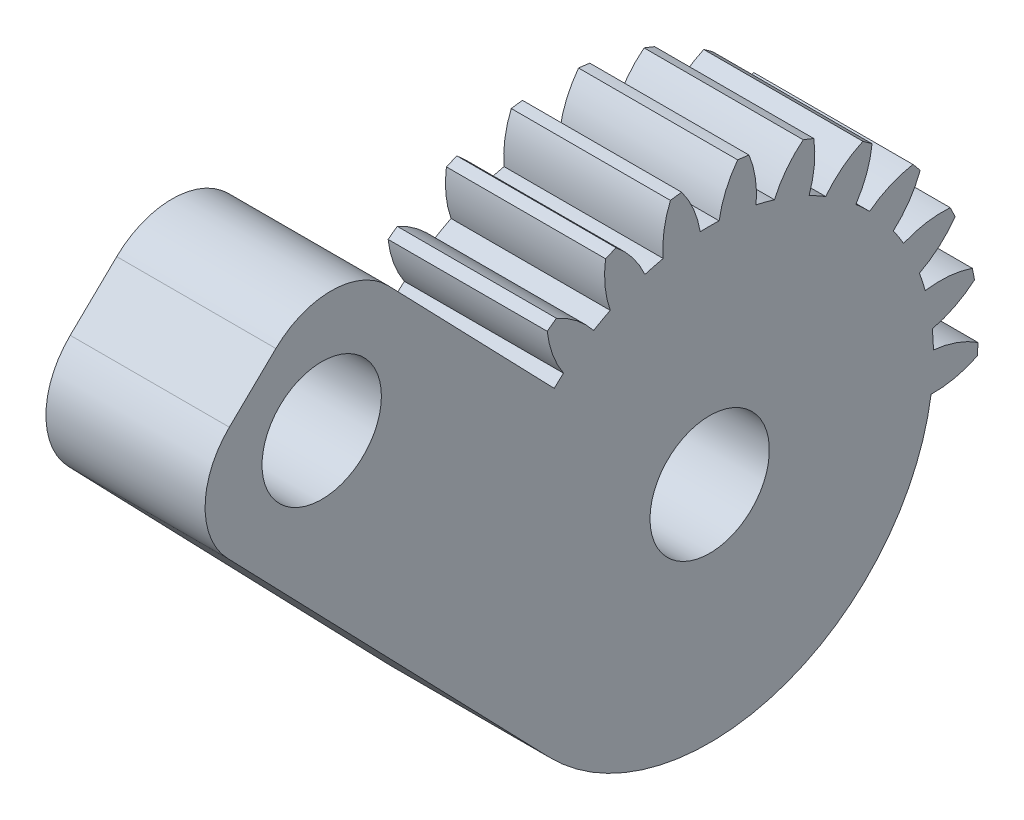
from build123d import *

# Parameters (mm, degrees)
BASPROSKE_W                  = 20
BASPROSKE_H                  = 33.75
BASE_REVOLVE_ANGLE           = 134
BASE_REVOLVE_OTHER_WAY_ANGLE = 11
TOOTHCUT_DEPTH               = 52.750603861
TEETHCUTS_COUNT              = 25
TEETHCUTS_ANGLE              = 345.6
BORSKE_R                     = 7.5
BORE_DEPTH                   = 50.000508
BOSS_EXTRUDE1_DEPTH          = 20
SKETCH5_R                    = 7.5
CUT_EXTRUDE1_DEPTH           = 20
FILLET1_R                    = 10
FILLET2_R                    = 10
SCALE1_SCALE                 = 0.8


with BuildPart() as part:
    # BasProSke → Base-Revolve (revolve)
    with BuildSketch(Plane(origin=(0, 0, 0), x_dir=(1, 0, 0), z_dir=(0, 1, 0))):
        with Locations((10, 16.875)):
            Rectangle(BASPROSKE_W, BASPROSKE_H)
    revolve(axis=Axis((-10, 0, 0), (1, 0, 0)), revolution_arc=BASE_REVOLVE_ANGLE)

    # BasProSke → Base-Revolve other way (revolve)
    with BuildSketch(Plane(origin=(0, 0, 0), x_dir=(1, 0, 0), z_dir=(0, 1, 0))):
        with Locations((10, 16.875)):
            Rectangle(BASPROSKE_W, BASPROSKE_H)
    revolve(axis=Axis((-10, 0, 0), (-1, 0, 0)), revolution_arc=BASE_REVOLVE_OTHER_WAY_ANGLE)

    # TooCutSke → ToothCut (cut, through all)
    with BuildSketch(Plane(origin=(0, 0, 0), x_dir=(0, 0, -1), z_dir=(1, 0, 0))):
        with BuildLine():
            ThreePointArc((1.187856988, 28.098903391), (0, 28.124), (-1.187856988, 28.098903391))
            ThreePointArc((-1.187856988, 28.098903391), (-2.083835169, 31.109603364), (-3.702102288, 33.801870579))
            ThreePointArc((-3.702102288, 33.801870579), (0, 34.004), (3.702102288, 33.801870579))
            ThreePointArc((3.702102288, 33.801870579), (2.083835169, 31.109603364), (1.187856988, 28.098903391))
        make_face()
    toothcut = extrude(amount=TOOTHCUT_DEPTH, mode=Mode.SUBTRACT)

    # TeethCuts: ToothCut ×25 about axis
    teethcuts_axis = Axis((-10, 0, 0), (1, 0, 0))
    for i in range(1, TEETHCUTS_COUNT):
        add(toothcut.rotate(teethcuts_axis, i * TEETHCUTS_ANGLE / (TEETHCUTS_COUNT - 1)), mode=Mode.SUBTRACT)

    # BorSke → Bore (cut, symmetric)
    with BuildSketch(Plane(origin=(0, 0, 0), x_dir=(0, 0, -1), z_dir=(1, 0, 0))):
        Circle(BORSKE_R)
    extrude(amount=BORE_DEPTH, both=True, mode=Mode.SUBTRACT)

    # Sketch4 → Boss-Extrude1 (add)
    with BuildSketch(Plane(origin=(20, 0, 0), x_dir=(0, 0, -1), z_dir=(1, 0, 0))):
        with BuildLine():
            Line((-67.553619374, 29.467732547), (-20.230712545, -19.536572011))
            ThreePointArc((-20.230712545, -19.536572011), (7.987647554, -26.965846223), (27.607282907, -5.366312186))
            Line((27.607282907, -5.366312186), (7.362203876, -1.431067465))
            ThreePointArc((7.362203876, -1.431067465), (-3.578690702, -6.591128345), (-5.209937778, 5.395048503))
            Line((-5.209937778, 5.395048503), (-47.322906829, 49.004304558))
            Line((-47.322906829, 49.004304558), (-67.553619374, 29.467732547))
        make_face()
    extrude(amount=-BOSS_EXTRUDE1_DEPTH)

    # Sketch5 → Cut-Extrude1 (cut)
    with BuildSketch(Plane(origin=(20, 0, 0), x_dir=(0, 0, -1), z_dir=(1, 0, 0))):
        with Locations((-48.755033471, 30.244271049)):
            Circle(SKETCH5_R)
    extrude(amount=-CUT_EXTRUDE1_DEPTH, mode=Mode.SUBTRACT)

    # Fillet1
    fillet1_edges = [part.edges().sort_by_distance(p)[0] for p in [
        (10, 49.004304558, 47.322906829),
    ]]
    fillet(fillet1_edges, radius=FILLET1_R)

    # Fillet2
    fillet2_edges = [part.edges().sort_by_distance(p)[0] for p in [
        (10, 29.467732547, 67.553619374),
    ]]
    fillet(fillet2_edges, radius=FILLET2_R)


with BuildPart() as part_1:
    # Scale1: scaled about (10, 7.017353876, 11.436425522)
    add(part.part.scale(SCALE1_SCALE).moved(Location((2, 1.403470775, 2.287285104))))


solid = part_1.part
